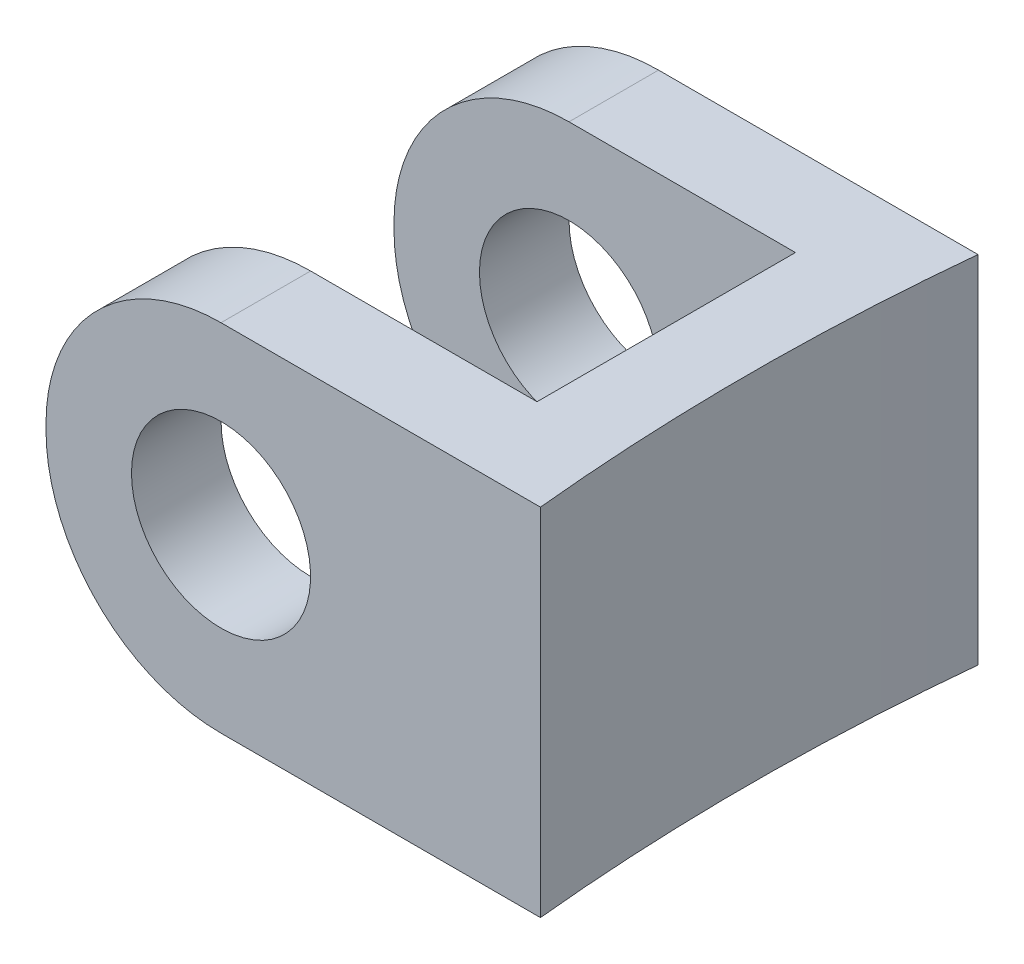
from build123d import *

# Parameters (mm, degrees)
BOSS_EXTRUDE2_DEPTH = 8.255
FILLET1_R           = 4.064
SKETCH2_R           = 2.07899
CUT_EXTRUDE1_DEPTH  = 11.16


with BuildPart() as part:
    # Sketch1 → Boss-Extrude2 (new body)
    with BuildSketch(Plane(origin=(0, 0, 0), x_dir=(1, 0, 0), z_dir=(0, 1, 0))):
        with BuildLine():
            Line((0, 0), (11.2268, 0))
            Line((11.2268, 0), (11.481438195, 0))
            ThreePointArc((11.481438195, 0), (11.2268, -5.08), (11.481438195, -10.16))
            Line((11.481438195, -10.16), (11.2268, -10.16))
            Line((11.2268, -10.16), (0, -10.16))
            Line((0, -10.16), (0, -8.07974))
            Line((0, -8.07974), (9.3218, -8.07974))
            Line((9.3218, -8.07974), (9.3218, -5.08))
            Line((9.3218, -5.08), (9.3218, -2.07974))
            Line((9.3218, -2.07974), (0, -2.07974))
            Line((0, -2.07974), (0, 0))
        make_face()
    extrude(amount=BOSS_EXTRUDE2_DEPTH)

    # Fillet1
    fillet1_edges = [part.edges().sort_by_distance(p)[0] for p in [
        (0, 0, 9.11987),
        (0, 0, 1.03987),
        (0, 8.255, 9.11987),
        (0, 8.255, 1.03987),
    ]]
    fillet(fillet1_edges, radius=FILLET1_R)

    # Sketch2 → Cut-Extrude1 (cut, through all)
    with BuildSketch(Plane(origin=(0, 0, 0), x_dir=(-1, 0, 0), z_dir=(0, 0, -1))):
        with Locations((-4.064, 4.191)):
            Circle(SKETCH2_R)
    extrude(amount=-CUT_EXTRUDE1_DEPTH, mode=Mode.SUBTRACT)


solid = part.part
